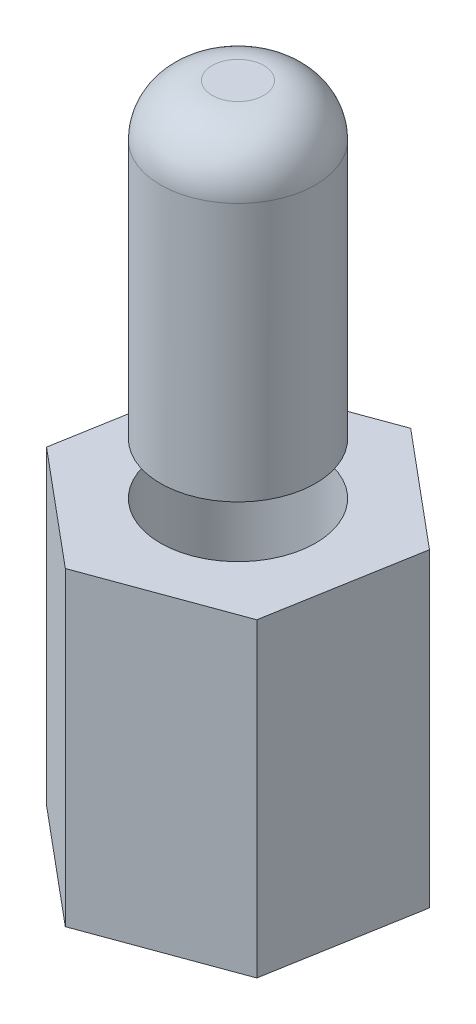
from build123d import *

# Parameters (mm, degrees)
BOSS_EXTRUDE1_DEPTH = 6
SKETCH2_R           = 1.5
BOSS_EXTRUDE2_DEPTH = 7
SKETCH3_R           = 1.5
CUT_EXTRUDE1_DEPTH  = 7
FILLET1_R           = 1


with BuildPart() as part:
    # Sketch1 → Boss-Extrude1 (new body)
    with BuildSketch(Plane(origin=(0, 0, 0), x_dir=(1, 0, 0), z_dir=(0, 1, 0))):
        Polygon((2.214824591, -1.851454932), (2.7108193, 0.992366895), (0.495994709, 2.843821827), (-2.214824591, 1.851454932), (-2.7108193, -0.992366895), (-0.495994709, -2.843821827), align=None)
    extrude(amount=BOSS_EXTRUDE1_DEPTH)

    # Sketch2 → Boss-Extrude2 (add)
    with BuildSketch(Plane(origin=(0, 6, 0), x_dir=(1, 0, 0), z_dir=(0, 1, 0))):
        Circle(SKETCH2_R)
    extrude(amount=BOSS_EXTRUDE2_DEPTH)

    # Sketch3 → Cut-Extrude1 (cut)
    with BuildSketch(Plane.XZ):
        Circle(SKETCH3_R)
    extrude(amount=-CUT_EXTRUDE1_DEPTH, mode=Mode.SUBTRACT)

    # Fillet1
    fillet1_edges = [part.edges().sort_by_distance(p)[0] for p in [
        (-1.5, 13, 0),
    ]]
    fillet(fillet1_edges, radius=FILLET1_R)


solid = part.part
